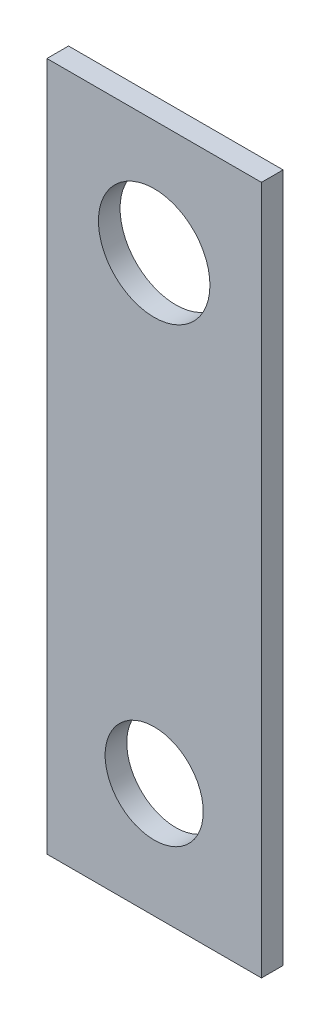
from build123d import *

# Parameters (mm, degrees)
SKETCH1_W           = 10.0838
SKETCH1_H           = 32.385
SKETCH1_R           = 2.619891049
SKETCH1_R_2         = 2.305481736
BOSS_EXTRUDE1_DEPTH = 1.016


with BuildPart() as part:
    # Sketch1 → Boss-Extrude1 (new body)
    with BuildSketch(Plane.XY):
        with Locations((5.0419, -16.1925)):
            Rectangle(SKETCH1_W, SKETCH1_H)
        with Locations((5.0419, -5.3975)):
            Circle(SKETCH1_R, mode=Mode.SUBTRACT)
        with Locations((5.0419, -26.9875)):
            Circle(SKETCH1_R_2, mode=Mode.SUBTRACT)
    extrude(amount=BOSS_EXTRUDE1_DEPTH)


solid = part.part
